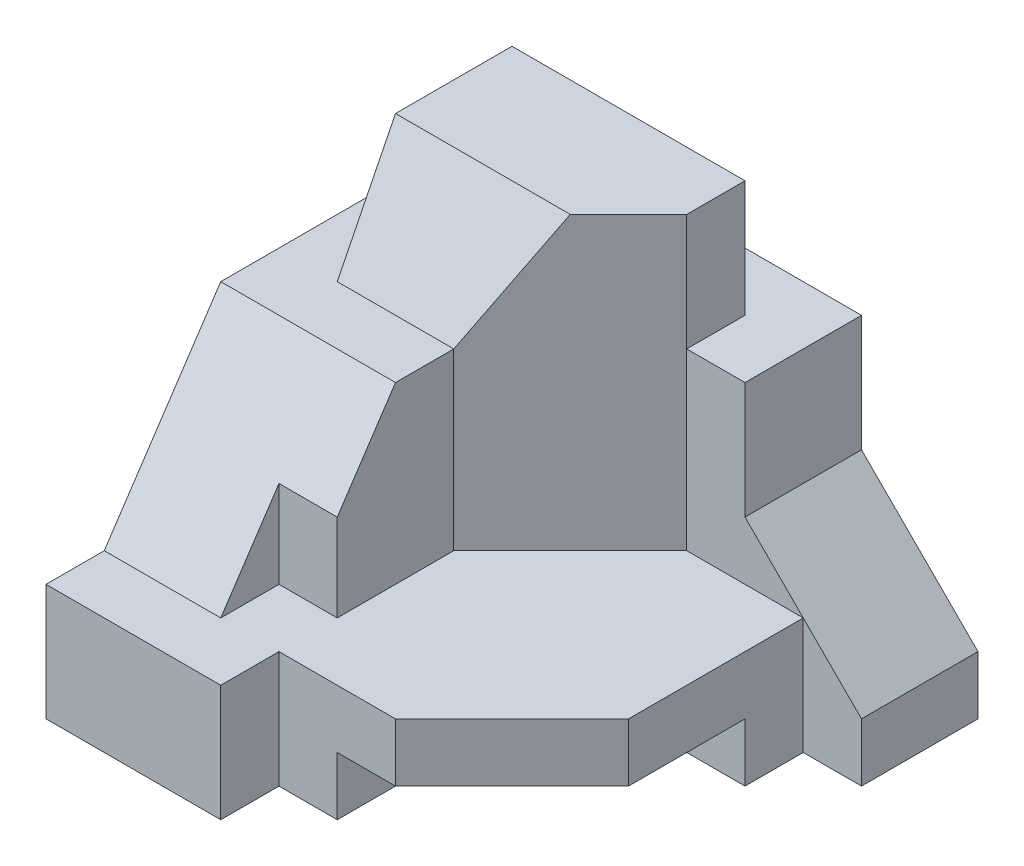
from build123d import *

# Parameters (mm, degrees)
SKETCH1_W           = 8
SKETCH1_H           = 7
BOSS_EXTRUDE3_DEPTH = 8
CUT_EXTRUDE1_DEPTH  = 8
CUT_EXTRUDE2_DEPTH  = 1
CUT_EXTRUDE4_DEPTH  = 2
CUT_EXTRUDE5_DEPTH  = 9
SKETCH7_OUTSIDE_W   = 12.66
SKETCH7_OUTSIDE_H   = 12.66
SKETCH7_OUTSIDE_W_2 = 4
SKETCH7_OUTSIDE_H_2 = 3
CUT_EXTRUDE6_DEPTH  = 2
SKETCH8_W           = 1
SKETCH8_H           = 1
CUT_EXTRUDE7_DEPTH  = 3
CUT_EXTRUDE8_DEPTH  = 5
SKETCH11_W          = 4
SKETCH11_H          = 2.236067977
CUT_EXTRUDE9_DEPTH  = 5
CUT_EXTRUDE10_DEPTH = 5
SKETCH13_W          = 2
SKETCH13_H          = 2
CUT_EXTRUDE12_DEPTH = 3


with BuildPart() as part:
    # Sketch1 → Boss-Extrude3 (new body)
    with BuildSketch(Plane.XY):
        Rectangle(SKETCH1_W, SKETCH1_H)
    extrude(amount=BOSS_EXTRUDE3_DEPTH)

    # Sketch3 → Cut-Extrude1 (cut, through all)
    with BuildSketch(Plane(origin=(0, 3.5, 0), x_dir=(1, 0, 0), z_dir=(0, 1, 0))):
        Polygon((4, -8), (4, -2), (3, -2), (3, -5), (1, -7), (-1, -7), (-1, -8), align=None)
    extrude(amount=-CUT_EXTRUDE1_DEPTH, mode=Mode.SUBTRACT)

    # Sketch4 → Cut-Extrude2 (cut)
    with BuildSketch(Plane.XZ.offset(3.5)):
        Polygon((1, 7), (3, 5), (3, 3), (0, 3), (0, 7), align=None)
    extrude(amount=-CUT_EXTRUDE2_DEPTH, mode=Mode.SUBTRACT)

    # Sketch5 → Cut-Extrude4 (cut)
    with BuildSketch(Plane(origin=(0, 0, 0), x_dir=(-1, 0, 0), z_dir=(0, 0, -1))):
        Polygon((-2, -0.5), (-2, 1.5), (-2, 3.5), (-4, 3.5), (-4, 1.5), (-4, -2.5), align=None)
    extrude(amount=-CUT_EXTRUDE4_DEPTH, mode=Mode.SUBTRACT)

    # Sketch6 → Cut-Extrude5 (cut, through all)
    with BuildSketch(Plane.ZY.offset(4)):
        Polygon((8, -1.5), (7, -1.5), (5, 1.5), (5, 3.5), (8, 3.5), align=None)
    extrude(amount=-CUT_EXTRUDE5_DEPTH, mode=Mode.SUBTRACT)

    # Sketch7 outside → Cut-Extrude6 (cut)
    with BuildSketch(Plane(origin=(0, 3.5, 0), x_dir=(1, 0, 0), z_dir=(0, 1, 0))):
        with Locations((0, -4)):
            Rectangle(SKETCH7_OUTSIDE_W, SKETCH7_OUTSIDE_H)
        with Locations((-1, -2.5)):
            Rectangle(SKETCH7_OUTSIDE_W_2, SKETCH7_OUTSIDE_H_2, mode=Mode.SUBTRACT)
    extrude(amount=-CUT_EXTRUDE6_DEPTH, mode=Mode.SUBTRACT)

    # Sketch8 → Cut-Extrude7 (cut)
    with BuildSketch(Plane(origin=(0, 1.5, 0), x_dir=(1, 0, 0), z_dir=(0, 1, 0))):
        with Locations((-1.5, -6.5)):
            Rectangle(SKETCH8_W, SKETCH8_H)
    extrude(amount=-CUT_EXTRUDE7_DEPTH, mode=Mode.SUBTRACT)

    # Sketch9 → Cut-Extrude8 (cut)
    with BuildSketch(Plane(origin=(0, 3.5, 0), x_dir=(1, 0, 0), z_dir=(0, 1, 0))):
        Polygon((-1, -6), (-1, -4), (3, -4), (3, -7), (-1, -7), align=None)
    extrude(amount=-CUT_EXTRUDE8_DEPTH, mode=Mode.SUBTRACT)

    # Sketch11 → Cut-Extrude9 (cut)
    with BuildSketch(Plane(origin=(0, 1.9, 3.8), x_dir=(1, 0, 0), z_dir=(0, 0.447213595, 0.894427191))):
        with Locations((-1, 0.670820394)):
            Rectangle(SKETCH11_W, SKETCH11_H)
    extrude(amount=CUT_EXTRUDE9_DEPTH, mode=Mode.SUBTRACT)

    # Sketch12 → Cut-Extrude10 (cut)
    with BuildSketch(Plane(origin=(0, 3.5, 0), x_dir=(1, 0, 0), z_dir=(0, 1, 0))):
        Polygon((1, -2), (-1, -4), (1, -4), align=None)
    extrude(amount=-CUT_EXTRUDE10_DEPTH, mode=Mode.SUBTRACT)

    # Sketch13 → Cut-Extrude12 (cut)
    with BuildSketch(Plane(origin=(0, 1.5, 0), x_dir=(1, 0, 0), z_dir=(0, 1, 0))):
        with Locations((2, -3)):
            Rectangle(SKETCH13_W, SKETCH13_H)
    extrude(amount=-CUT_EXTRUDE12_DEPTH, mode=Mode.SUBTRACT)


solid = part.part
